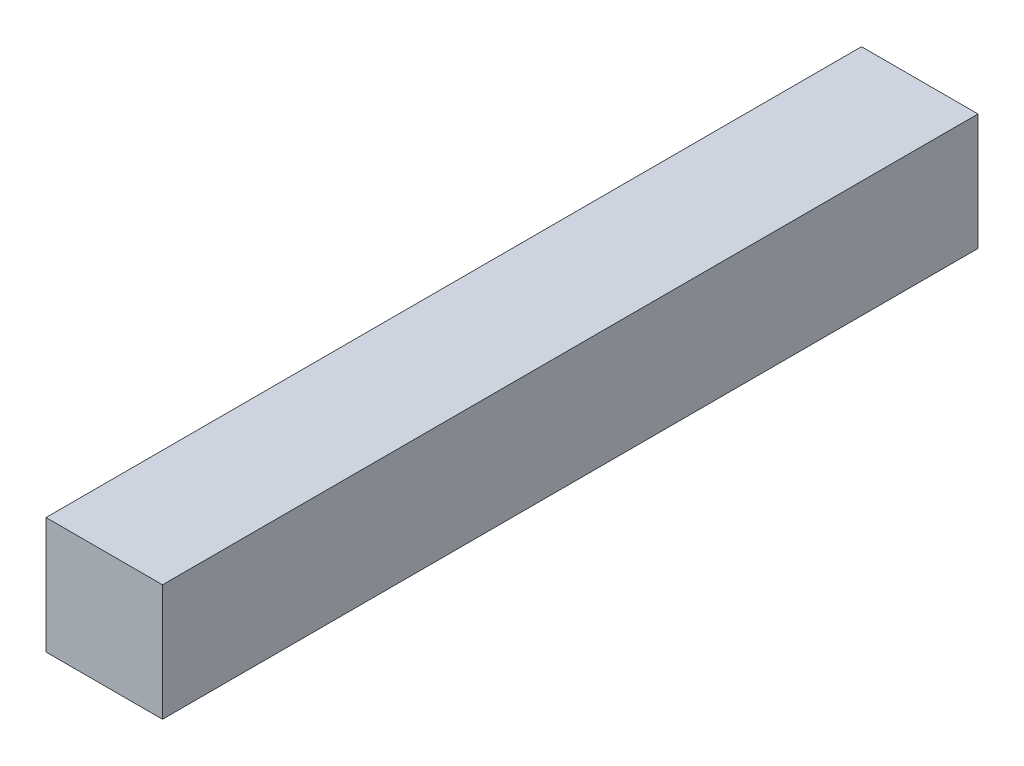
from build123d import *

# Parameters (mm, degrees)
SKETCH1_W           = 50
SKETCH1_H           = 50
BOSS_EXTRUDE1_DEPTH = 350


with BuildPart() as part:
    # Sketch1 → Boss-Extrude1 (new body)
    with BuildSketch(Plane.XY):
        Rectangle(SKETCH1_W, SKETCH1_H)
    extrude(amount=BOSS_EXTRUDE1_DEPTH)


solid = part.part
